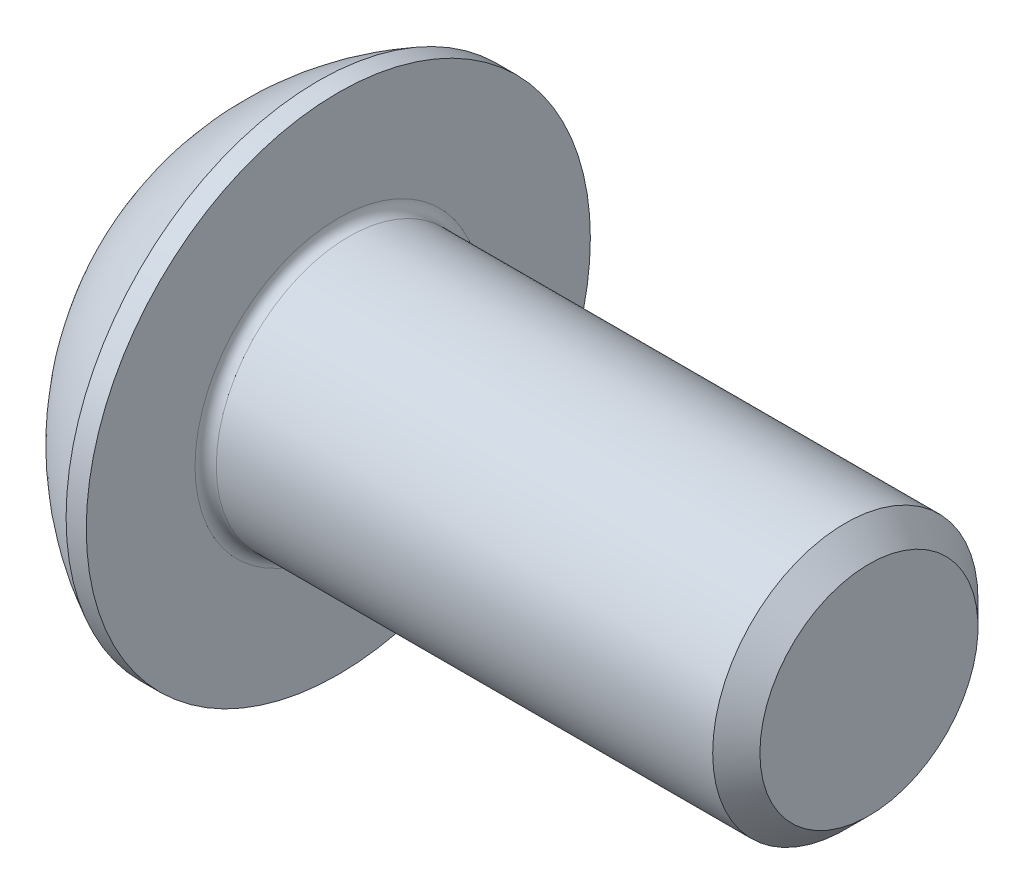
from build123d import *

# Parameters (mm, degrees)
FILLET1_R   = 0.2
HEX_2_DEPTH = 1.56


with BuildPart() as part:
    # BodySke → BaseBody (revolve)
    with BuildSketch(Plane.XY):
        with BuildLine():
            Line((12.75, 0), (12.75, 2.055))
            Line((12.75, 2.055), (12.305, 2.5))
            Line((12.305, 2.5), (2.75, 2.5))
            Line((2.75, 2.5), (2.75, 4.75))
            Line((2.75, 4.75), (2.37, 4.75))
            ThreePointArc((2.37, 4.75), (0.992680215, 3.754414901), (0, 2.375))
            Line((0, 2.375), (0, 0))
            Line((0, 0), (12.75, 0))
        make_face()
    revolve(axis=Axis((0, 0, 0), (1, 0, 0)))

    # Fillet1
    fillet1_edges = [part.edges().sort_by_distance(p)[0] for p in [
        (2.75, -2.5, 0),
    ]]
    fillet(fillet1_edges, radius=FILLET1_R)

    # Sketch2 → PreBroach (revolve, cut)
    with BuildSketch(Plane.XY):
        Polygon((0, 1.5), (1.56, 1.5), (2.426025404, 0), (0, 0), align=None)
    revolve(axis=Axis((0, 0, 0), (1, 0, 0)), mode=Mode.SUBTRACT)

    # Sketch3 → Hex 2 (cut)
    with BuildSketch(Plane(origin=(0, 0, 0), x_dir=(0, 0, -1), z_dir=(1, 0, 0))):
        Polygon((-1.5, -0.866025404), (-1.5, 0.866025404), (0, 1.732050808), (1.5, 0.866025404), (1.5, -0.866025404), (0, -1.732050808), align=None)
    extrude(amount=HEX_2_DEPTH, mode=Mode.SUBTRACT)


solid = part.part
